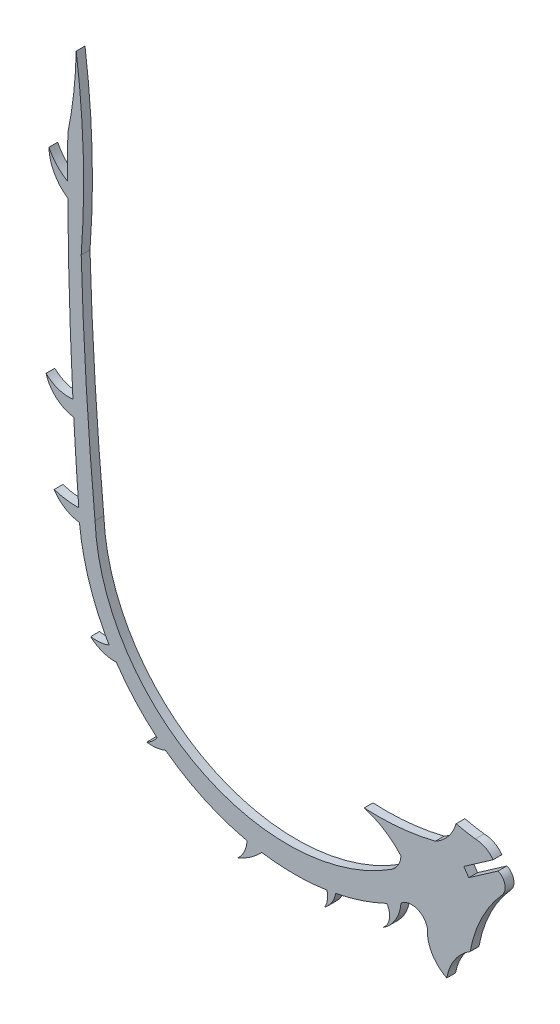
from build123d import *

# Parameters (mm, degrees)
BOSS_EXTRUDE1_DEPTH = 1.524


with BuildPart() as part:
    # Sketch1 → Boss-Extrude1 (new body)
    with BuildSketch(Plane.XY):
        with BuildLine():
            Line((37.704296416, -31.705702494), (32.621666071, -35.245462588))
            Line((32.621666071, -35.245462588), (33.493939306, -36.4982372))
            Line((33.493939306, -36.4982372), (38.576569651, -32.957484201))
            ThreePointArc((38.576569651, -32.957484201), (39.742986246, -34.371130843), (39.316039794, -36.153444291))
            ThreePointArc((39.316039794, -36.153444291), (35.743862713, -41.392315435), (33.736249861, -47.406940162))
            ThreePointArc((33.736249861, -47.406940162), (33.736605397, -47.436618983), (33.736723912, -47.466299698))
            ThreePointArc((33.736723912, -47.466299698), (31.060825363, -50.029100651), (29.678991539, -53.46696584))
            ThreePointArc((29.678991539, -53.46696584), (27.115500093, -51.083388449), (26.30925741, -47.677085129))
            ThreePointArc((26.30925741, -47.677085129), (24.451153983, -45.627042683), (21.740362101, -46.180964831))
            ThreePointArc((21.740362101, -46.180964831), (20.76513964, -49.206145699), (18.541417724, -51.477233316))
            ThreePointArc((18.541417724, -51.477233316), (19.716696181, -49.619411518), (19.289312359, -47.462996819))
            ThreePointArc((19.289312359, -47.462996819), (14.95515305, -49.204688548), (10.437184098, -50.390598976))
            ThreePointArc((10.437184098, -50.390598976), (9.740523804, -52.101024231), (8.47892764, -53.449825638))
            ThreePointArc((8.47892764, -53.449825638), (8.977567303, -52.098435339), (8.892067822, -50.66052467))
            ThreePointArc((8.892067822, -50.66052467), (3.246101629, -51.089737509), (-2.399729403, -50.658750414))
            ThreePointArc((-2.399729403, -50.658750414), (-4.344989088, -52.336657488), (-6.594422726, -53.577405529))
            ThreePointArc((-6.594422726, -53.577405529), (-5.427176524, -52.043650888), (-4.956013668, -50.174728054))
            ThreePointArc((-4.956013668, -50.174728054), (-12.354481608, -47.665032068), (-19.067256704, -43.668214296))
            ThreePointArc((-19.067256704, -43.668214296), (-20.685168003, -44.086118721), (-22.356101471, -44.069919276))
            ThreePointArc((-22.356101471, -44.069919276), (-21.34731349, -43.406825821), (-20.564738203, -42.48762941))
            ThreePointArc((-20.564738203, -42.48762941), (-24.363722181, -38.849120016), (-27.612631699, -34.712017549))
            ThreePointArc((-27.612631699, -34.712017549), (-30.00052566, -34.336897034), (-32.065024234, -33.079678433))
            ThreePointArc((-32.065024234, -33.079678433), (-30.436493757, -33.12678938), (-28.850067174, -32.755869369))
            ThreePointArc((-28.850067174, -32.755869369), (-29.339652087, -31.900308765), (-29.806440493, -31.032100312))
            ThreePointArc((-29.806440493, -31.032100312), (-32.582725704, -24.1759064), (-34.009509312, -16.917845842))
            ThreePointArc((-34.009509312, -16.917845842), (-36.514142372, -16.032312472), (-38.402522283, -14.16378968))
            ThreePointArc((-38.402522283, -14.16378968), (-36.306570998, -14.636822999), (-34.162260401, -14.773586932))
            ThreePointArc((-34.162260401, -14.773586932), (-34.180156343, -14.293685665), (-34.192120126, -13.813599883))
            ThreePointArc((-34.192120126, -13.813599883), (-34.621527317, -7.717500789), (-34.994580248, -1.617693725))
            ThreePointArc((-34.994580248, -1.617693725), (-38.013814487, -0.220962087), (-39.79584853, 2.588128395))
            ThreePointArc((-39.79584853, 2.588128395), (-37.649043689, 1.2668877), (-35.139082483, 1.033343809))
            ThreePointArc((-35.139082483, 1.033343809), (-35.751631039, 15.891841194), (-36.02990482, 30.760355712))
            ThreePointArc((-36.02990482, 30.760355712), (-38.387515912, 33.373438153), (-39.306278852, 36.770849603))
            ThreePointArc((-39.306278852, 36.770849603), (-37.931736179, 34.774118143), (-36.043826919, 33.253558144))
            ThreePointArc((-36.043826919, 33.253558144), (-36.047258198, 36.901464596), (-36.030566217, 40.549334472))
            ThreePointArc((-36.030566217, 40.549334472), (-35.002266591, 47.029894856), (-34.571956243, 53.577405529))
            ThreePointArc((-34.571956243, 53.577405529), (-33.341283224, 38.509314077), (-33.703754569, 23.395394975))
            ThreePointArc((-33.703754569, 23.395394975), (-32.823671192, 4.023096585), (-31.30799989, -15.309860564))
            ThreePointArc((-31.30799989, -15.309860564), (-13.310528761, -43.455618792), (20.06424012, -41.96649978))
            ThreePointArc((20.06424012, -41.96649978), (21.243050758, -40.73566209), (21.723238049, -39.10043241))
            ThreePointArc((21.723238049, -39.10043241), (18.8276625, -36.637371423), (15.353729803, -35.093733252))
            ThreePointArc((15.353729803, -35.093733252), (21.571557105, -34.969630573), (27.700749295, -33.916169174))
            ThreePointArc((27.700749295, -33.916169174), (29.941679247, -32.068657032), (31.293105646, -29.497914951))
            ThreePointArc((31.293105646, -29.497914951), (32.948684374, -29.840980808), (34.616890834, -30.116157682))
            ThreePointArc((34.616890834, -30.116157682), (36.353174649, -30.536876005), (37.704296416, -31.705702494))
        make_face()
    extrude(amount=BOSS_EXTRUDE1_DEPTH)


solid = part.part
